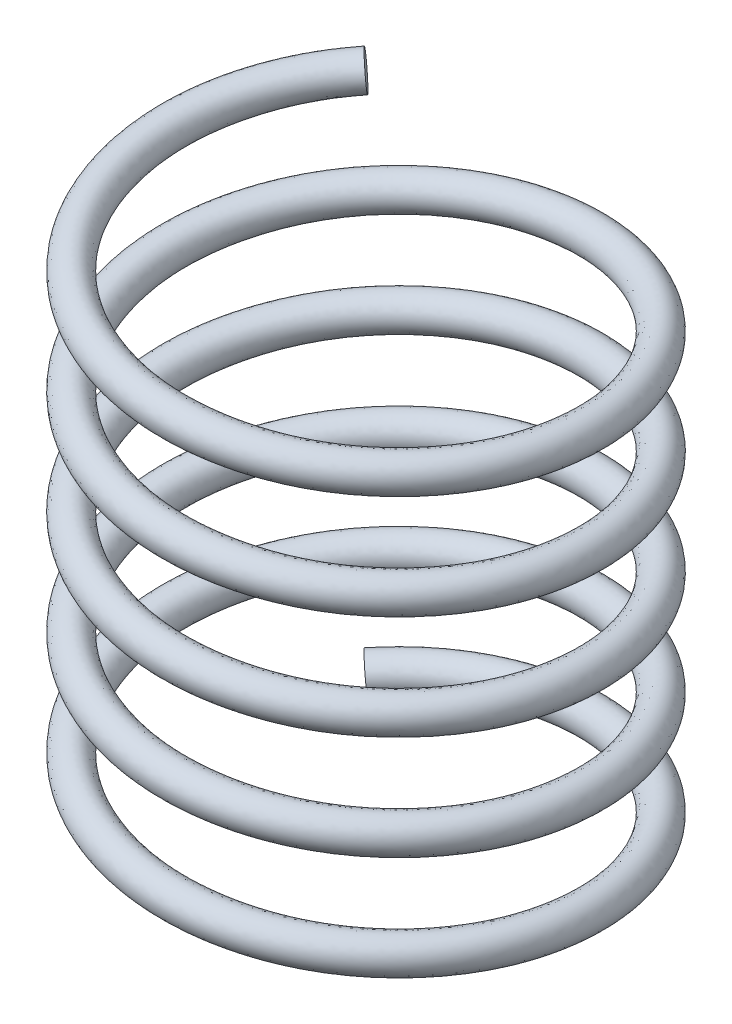
from build123d import *

# Parameters (mm, degrees)
SWEEP2_PITCH       = 3
SWEEP2_HEIGHT      = 15
SWEEP2_RADIUS      = 6
SWEEP2_START_ANGLE = -135
SKETCH4_R          = 0.5


with BuildPart() as part:
    # Sweep2: sweep along a helix
    with BuildLine() as sweep2_path:
        add(Helix(SWEEP2_PITCH, SWEEP2_HEIGHT, SWEEP2_RADIUS, center=(0, 0, 0), direction=(0, 1, 0), lefthand=True, mode=Mode.PRIVATE).rotate(Axis((0, 0, 0), (0, 1, 0)), SWEEP2_START_ANGLE))
    # Sketch4 → Sweep2 (sweep)
    with BuildSketch(Plane(origin=(-4.242640687, 0, -4.242640687), x_dir=(-0.709328106, 0.078829077, -0.700456718), z_dir=(0.704878456, 0.079326697, -0.704878456))):
        with Locations((0.002039346, 0.000799599)):
            Circle(SKETCH4_R)
    sweep(path=sweep2_path.line, is_frenet=True)


solid = part.part
